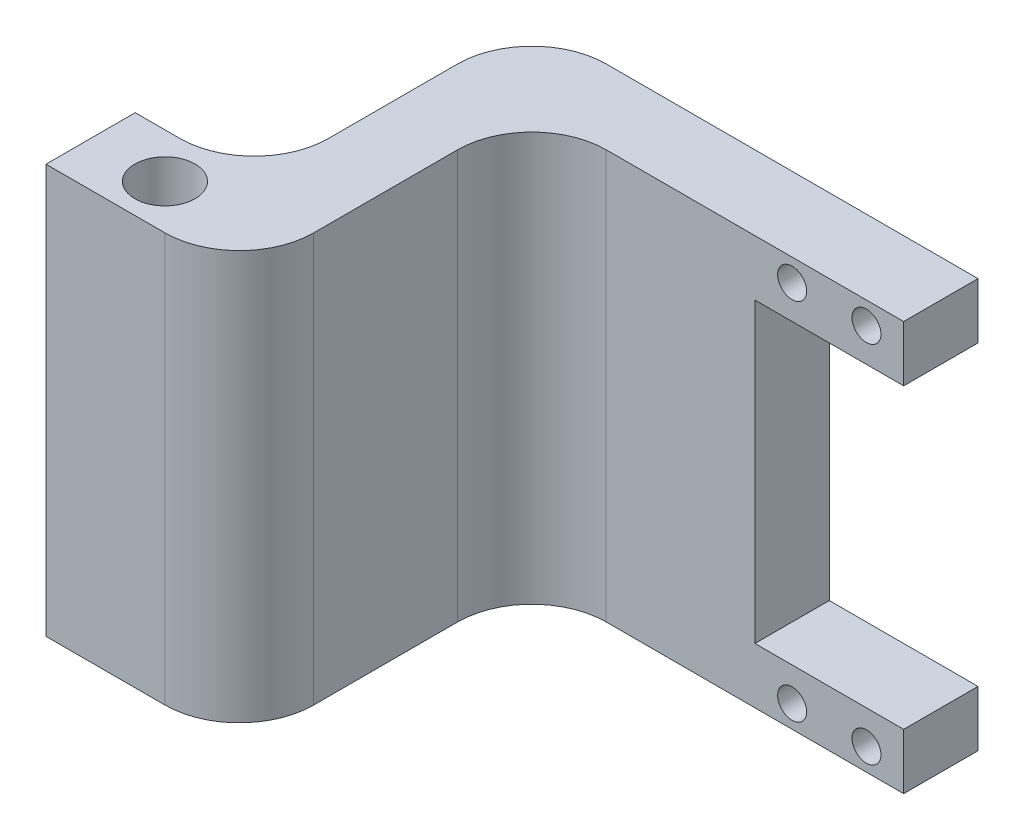
from build123d import *

# Parameters (mm, degrees)
SKETCH1_W           = 20
SKETCH1_H           = 7.5
SKETCH1_R           = 1.95
BOSS_EXTRUDE2_DEPTH = 10
SKETCH3_W           = 49.35
SKETCH3_H           = 55
BOSS_EXTRUDE3_DEPTH = 10
SKETCH4_W           = 16
SKETCH4_H           = 12
SKETCH4_R           = 4.05
BOSS_EXTRUDE4_DEPTH = 55
SKETCH5_R           = 1.45
CUT_EXTRUDE1_DEPTH  = 10
FILLET1_R           = 10


with BuildPart() as part:
    # Sketch1 → Boss-Extrude2 (new body)
    with BuildSketch(Plane.XY):
        Polygon((-10, 27.5), (-40, 27.5), (-40, -27.5), (-10, -27.5), (-10, -20), (-10, 20), align=None)
        with Locations((0, 23.75)):
            Rectangle(SKETCH1_W, SKETCH1_H)
        with Locations((5, 24.5)):
            Circle(SKETCH1_R, mode=Mode.SUBTRACT)
        with Locations((-5, 24.5)):
            Circle(SKETCH1_R, mode=Mode.SUBTRACT)
        with Locations((0, -23.75)):
            Rectangle(SKETCH1_W, SKETCH1_H)
        with Locations((5, -24.5)):
            Circle(SKETCH1_R, mode=Mode.SUBTRACT)
        with Locations((-5, -24.5)):
            Circle(SKETCH1_R, mode=Mode.SUBTRACT)
    extrude(amount=BOSS_EXTRUDE2_DEPTH)

    # Sketch3 → Boss-Extrude3 (add)
    with BuildSketch(Plane.ZY.offset(40)):
        with Locations((24.675, 0)):
            Rectangle(SKETCH3_W, SKETCH3_H)
    extrude(amount=BOSS_EXTRUDE3_DEPTH)

    # Sketch4 → Boss-Extrude4 (add)
    with BuildSketch(Plane.XZ.offset(27.5)):
        with Locations((-58, 43.35)):
            Rectangle(SKETCH4_W, SKETCH4_H)
        with Locations((-56, 43.35)):
            Circle(SKETCH4_R, mode=Mode.SUBTRACT)
    extrude(amount=-BOSS_EXTRUDE4_DEPTH)

    # Sketch5 → Cut-Extrude1 (cut)
    with BuildSketch(Plane.ZY.offset(66)):
        with Locations((43.35, 20)):
            Circle(SKETCH5_R)
        with Locations((43.35, 0)):
            Circle(SKETCH5_R)
        with Locations((43.35, -20)):
            Circle(SKETCH5_R)
    extrude(amount=-CUT_EXTRUDE1_DEPTH, mode=Mode.SUBTRACT)

    # Fillet1
    fillet1_edges = [part.edges().sort_by_distance(p)[0] for p in [
        (-40, 0, 10),
        (-40, 0, 49.35),
        (-50, 0, 0),
        (-50, 0, 37.35),
    ]]
    fillet(fillet1_edges, radius=FILLET1_R)


solid = part.part
